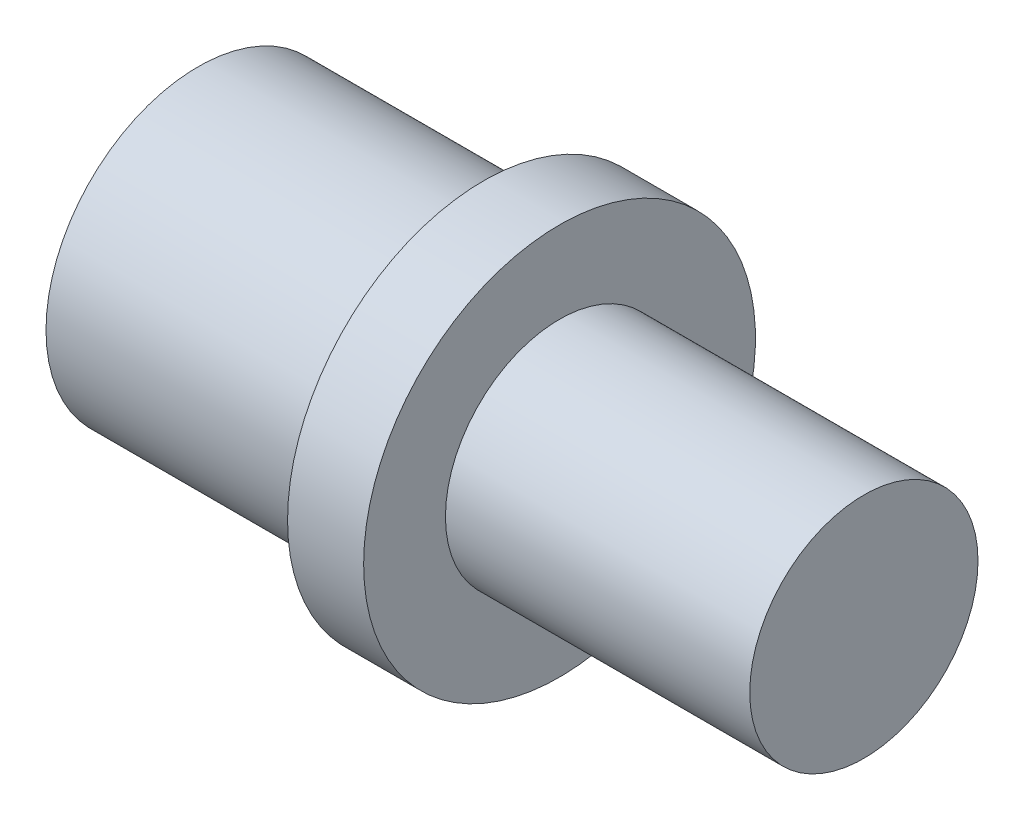
from build123d import *

# Parameters (mm, degrees)
CUT_EXTRUDE3_DEPTH = 2.5


with BuildPart() as part:
    # Sketch1 → Revolve1 (revolve)
    with BuildSketch(Plane.XY):
        Polygon((-9.5, 0), (8, 0), (8, 3), (0, 3), (0, 5.15), (-2, 5.15), (-2, 4), (-9.5, 4), (-9, 3.2), (-9.5, 3.2), align=None)
    revolve(axis=Axis((-9.190479794, 0, 0), (1, 0, 0)))

    # Sketch5 → Cut-Revolve1 (revolve, cut)
    with BuildSketch(Plane.XY):
        Polygon((-9.5, 2.5), (-7, 2.5), (-5.497848452, 0), (-9.5, 0), align=None)
    revolve(axis=Axis((-9.5, 0, 0), (1, 0, 0)), mode=Mode.SUBTRACT)

    # Sketch4 → Cut-Extrude3 (cut)
    with BuildSketch(Plane(origin=(-9.5, 0, 0), x_dir=(0, 0, -1), z_dir=(1, 0, 0))):
        Polygon((0, 2.886751346), (-2.5, 1.443375673), (-2.5, -1.443375673), (0, -2.886751346), (2.5, -1.443375673), (2.5, 1.443375673), align=None)
    extrude(amount=CUT_EXTRUDE3_DEPTH, mode=Mode.SUBTRACT)


solid = part.part
